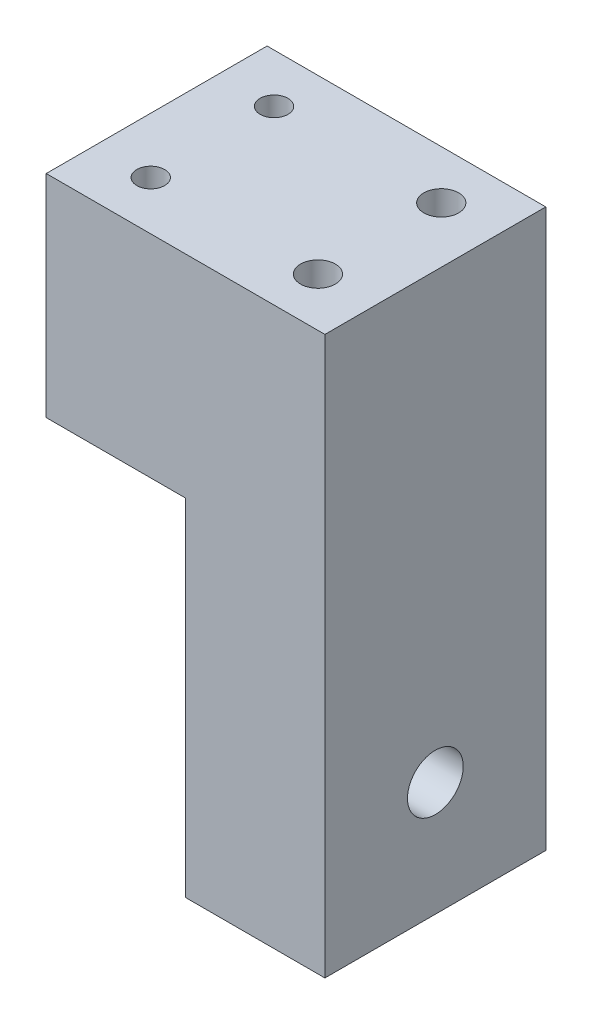
from build123d import *

# Parameters (mm, degrees)
SKETCH1_W                 = 20
SKETCH1_H                 = 31.7
BOSS_EXTRUDE1_DEPTH       = 80
CUT_EXTRUDE1_REACH        = 22
SKETCH2_R                 = 4
M3X0_5_TAPPED_HOLE1_D     = 2.5
M3X0_5_TAPPED_HOLE1_DEPTH = 7.5
M3X0_5_TAPPED_HOLE1_TIP   = 0.751075774
SKETCH5_W                 = 31.7
SKETCH5_H                 = 30.344547228
BOSS_EXTRUDE2_DEPTH       = 20
F_4_0MM_DOWEL_HOLE1_D     = 4
F_4_0MM_DOWEL_HOLE1_DEPTH = 5.2
F_4_0MM_DOWEL_HOLE1_TIP   = 1.201721238
M6X1_0_TAPPED_HOLE1_D     = 5
M6X1_0_TAPPED_HOLE1_DEPTH = 15
M6X1_0_TAPPED_HOLE1_TIP   = 1.502151548


with BuildPart() as part:
    # Sketch1 → Boss-Extrude1 (new body)
    with BuildSketch(Plane(origin=(0, 0, 0), x_dir=(1, 0, 0), z_dir=(0, 1, 0))):
        with Locations((5.656892123, -4.053125)):
            Rectangle(SKETCH1_W, SKETCH1_H)
    extrude(amount=BOSS_EXTRUDE1_DEPTH)

    # Sketch2 → Cut-Extrude1 (cut, up to next)
    with BuildSketch(Plane.ZY.offset(4.343107877), mode=Mode.PRIVATE) as cut_extrude1_sk1:
        with Locations((4.053125, 16.390354737)):
            Circle(SKETCH2_R)
    cut_extrude1_tool1 = extrude(cut_extrude1_sk1.sketch, amount=-CUT_EXTRUDE1_REACH, mode=Mode.PRIVATE) & part.part
    add(cut_extrude1_tool1.solids().sort_by_distance((-4.343108, 16.390355, 4.053125))[0], mode=Mode.SUBTRACT)

    # M3x0.5 Tapped Hole1
    with Locations(Plane.ZY.offset(4.343107877)):
        with Locations((16.604270366, 28.941500103), (-8.498020366, 28.941500103), (-8.498020366, 3.839209371), (16.604270366, 3.839209371)):
            Hole(M3X0_5_TAPPED_HOLE1_D / 2, depth=M3X0_5_TAPPED_HOLE1_DEPTH)
            with Locations((0, 0, -(M3X0_5_TAPPED_HOLE1_DEPTH + M3X0_5_TAPPED_HOLE1_TIP / 2))):  # 118° drill point
                Cone(0, M3X0_5_TAPPED_HOLE1_D / 2, M3X0_5_TAPPED_HOLE1_TIP, mode=Mode.SUBTRACT)

    # Sketch5 → Boss-Extrude2 (add)
    with BuildSketch(Plane.ZY.offset(4.343107877)):
        with Locations((4.053125, 64.827726386)):
            Rectangle(SKETCH5_W, SKETCH5_H)
    extrude(amount=BOSS_EXTRUDE2_DEPTH)

    # Ø4.0mm Dowel Hole1
    with Locations(Plane(origin=(0, 80, 0), x_dir=(1, 0, 0), z_dir=(0, 1, 0))):
        with Locations((-16.343107877, 4.796875), (-16.343107877, -12.903125)):
            Hole(F_4_0MM_DOWEL_HOLE1_D / 2, depth=F_4_0MM_DOWEL_HOLE1_DEPTH)
            with Locations((0, 0, -(F_4_0MM_DOWEL_HOLE1_DEPTH + F_4_0MM_DOWEL_HOLE1_TIP / 2))):  # 118° drill point
                Cone(0, F_4_0MM_DOWEL_HOLE1_D / 2, F_4_0MM_DOWEL_HOLE1_TIP, mode=Mode.SUBTRACT)

    # M6x1.0 Tapped Hole1
    with Locations(Plane(origin=(0, 80, 0), x_dir=(1, 0, 0), z_dir=(0, 1, 0))):
        with Locations((7.656892123, 4.796875), (7.656892123, -12.903125)):
            Hole(M6X1_0_TAPPED_HOLE1_D / 2, depth=M6X1_0_TAPPED_HOLE1_DEPTH)
            with Locations((0, 0, -(M6X1_0_TAPPED_HOLE1_DEPTH + M6X1_0_TAPPED_HOLE1_TIP / 2))):  # 118° drill point
                Cone(0, M6X1_0_TAPPED_HOLE1_D / 2, M6X1_0_TAPPED_HOLE1_TIP, mode=Mode.SUBTRACT)


solid = part.part
